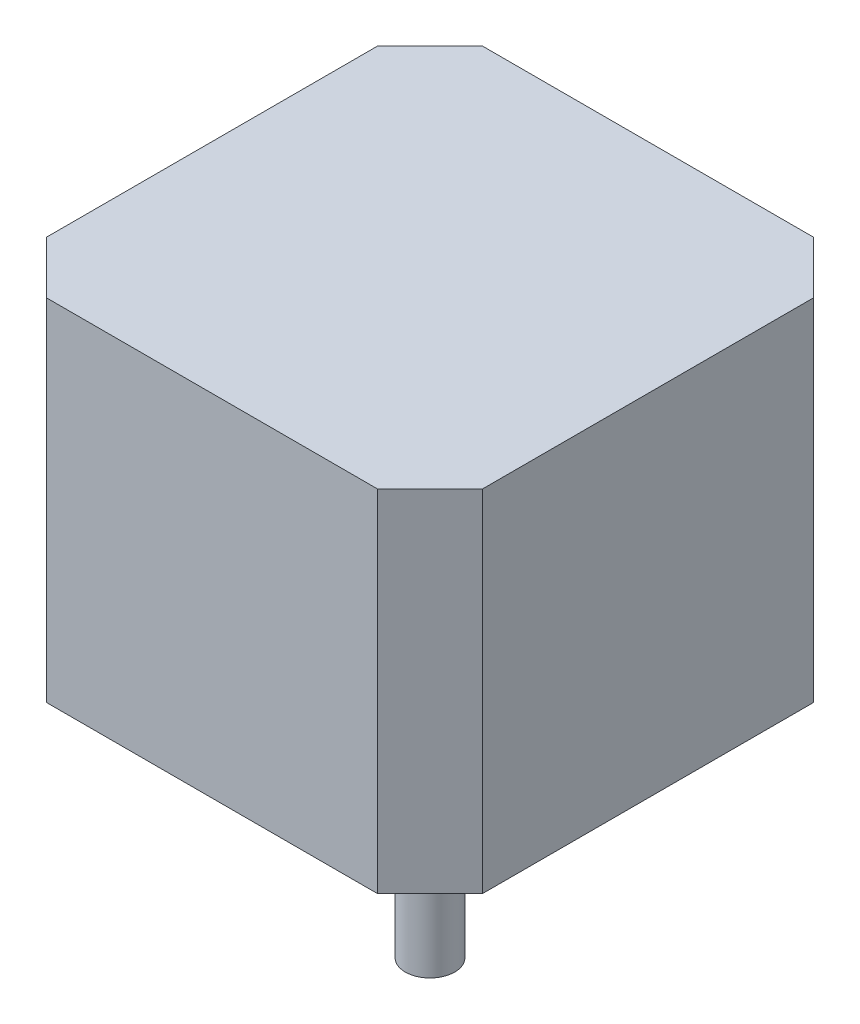
from build123d import *

# Parameters (mm, degrees)
BOSS_EXTRUDE1_DEPTH       = 34
M3X0_5_TAPPED_HOLE1_D     = 2.5
M3X0_5_TAPPED_HOLE1_DEPTH = 4.499991
M3X0_5_TAPPED_HOLE1_TIP   = 0.751075774
SKETCH4_R                 = 11
BOSS_EXTRUDE2_DEPTH       = 2
BOSS_EXTRUDE3_DEPTH       = 22


with BuildPart() as part:
    # Sketch1 → Boss-Extrude1 (new body)
    with BuildSketch(Plane(origin=(0, 0, 0), x_dir=(1, 0, 0), z_dir=(0, 1, 0))):
        Polygon((-21.15, -16.07), (-21.15, 16.07), (-16.07, 21.15), (16.07, 21.15), (21.15, 16.07), (21.15, -16.07), (16.07, -21.15), (-16.07, -21.15), align=None)
    extrude(amount=BOSS_EXTRUDE1_DEPTH)

    # M3x0.5 Tapped Hole1
    with Locations(Plane(origin=(0, 0, 0), x_dir=(-1, 0, 0), z_dir=(0, -1, 0))):
        with Locations((-15.5, 15.5), (15.5, 15.5), (15.5, -15.5), (-15.5, -15.5)):
            Hole(M3X0_5_TAPPED_HOLE1_D / 2, depth=M3X0_5_TAPPED_HOLE1_DEPTH)
            with Locations((0, 0, -(M3X0_5_TAPPED_HOLE1_DEPTH + M3X0_5_TAPPED_HOLE1_TIP / 2))):  # 118° drill point
                Cone(0, M3X0_5_TAPPED_HOLE1_D / 2, M3X0_5_TAPPED_HOLE1_TIP, mode=Mode.SUBTRACT)

    # Sketch4 → Boss-Extrude2 (add)
    with BuildSketch(Plane(origin=(0, 0, 0), x_dir=(-1, 0, 0), z_dir=(0, -1, 0))):
        Circle(SKETCH4_R)
    extrude(amount=BOSS_EXTRUDE2_DEPTH)

    # Sketch5 → Boss-Extrude3 (add)
    with BuildSketch(Plane.XZ.offset(2)):
        with BuildLine():
            Line((1.524, -1.848854431), (-1.524, -1.848854431))
            ThreePointArc((-1.524, -1.848854431), (0, 2.396004738), (1.524, -1.848854431))
        make_face()
    extrude(amount=BOSS_EXTRUDE3_DEPTH)


solid = part.part
